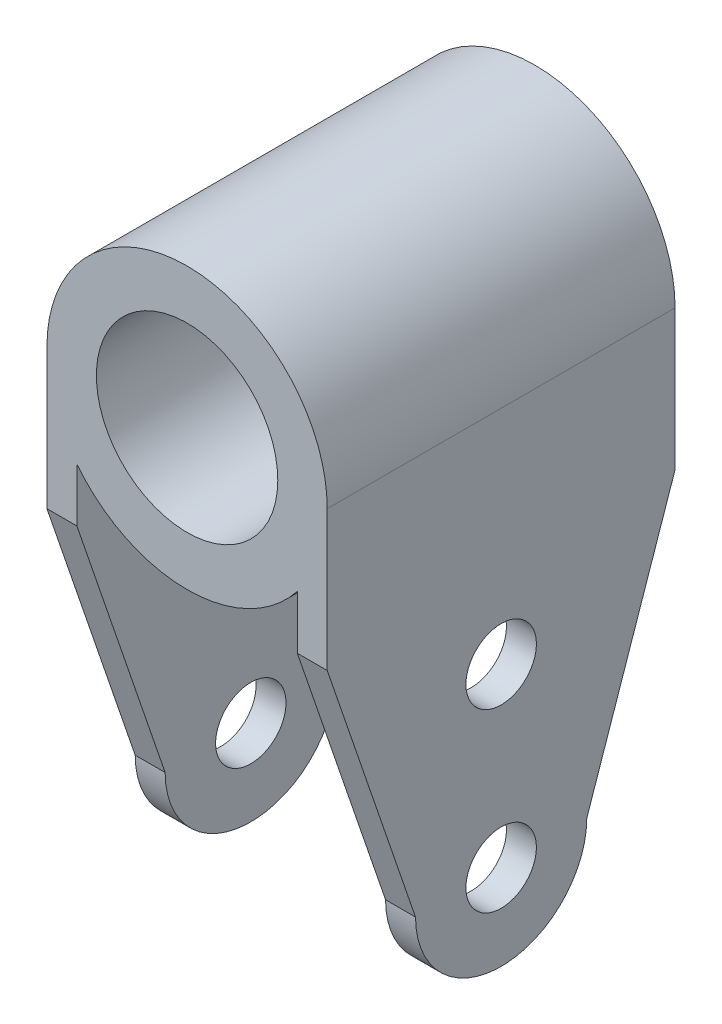
from build123d import *

# Parameters (mm, degrees)
SKETCH2_R            = 10.3
BOSS_EXTRUDE1_DEPTH  = 39.5
CUT_EXTRUDE1_DEPTH   = 32.83
M7_CLEARANCE_HOLE1_D = 8


with BuildPart() as part:
    # Sketch2 → Boss-Extrude1 (new body)
    with BuildSketch(Plane.XY):
        with BuildLine():
            Line((-15.915, 0), (-15.915, -15.915))
            Line((-15.915, -15.915), (-15.915, -54.9))
            Line((-15.915, -54.9), (-12.515, -54.9))
            Line((-12.515, -54.9), (-12.515, -9.831683477))
            ThreePointArc((-12.515, -9.831683477), (0, -15.915), (12.515, -9.831683477))
            Line((12.515, -9.831683477), (12.515, -54.9))
            Line((12.515, -54.9), (15.915, -54.9))
            Line((15.915, -54.9), (15.915, -27.45))
            Line((15.915, -27.45), (15.915, 0))
            ThreePointArc((15.915, 0), (0, 15.915), (-15.915, 0))
        make_face()
        Circle(SKETCH2_R, mode=Mode.SUBTRACT)
    extrude(amount=BOSS_EXTRUDE1_DEPTH)

    # Sketch3 → Cut-Extrude1 (cut, through all)
    with BuildSketch(Plane.ZY.offset(15.915)):
        with BuildLine():
            ThreePointArc((19.75, -54.9), (12.873386553, -52.051613447), (10.025, -45.175))
            Line((10.025, -45.175), (0, -15.915))
            Line((0, -15.915), (0, -54.9))
            Line((0, -54.9), (19.75, -54.9))
        make_face()
        with BuildLine():
            Line((39.5, -15.915), (29.475, -45.175))
            ThreePointArc((29.475, -45.175), (26.626613447, -52.051613447), (19.75, -54.9))
            Line((19.75, -54.9), (39.5, -54.9))
            Line((39.5, -54.9), (39.5, -15.915))
        make_face()
    extrude(amount=-CUT_EXTRUDE1_DEPTH, mode=Mode.SUBTRACT)

    # M7 Clearance Hole1 (through all)
    with Locations(Plane.ZY.offset(15.915)):
        with Locations((19.75, -45.175), (19.75, -25.175)):
            Hole(M7_CLEARANCE_HOLE1_D / 2)


solid = part.part
